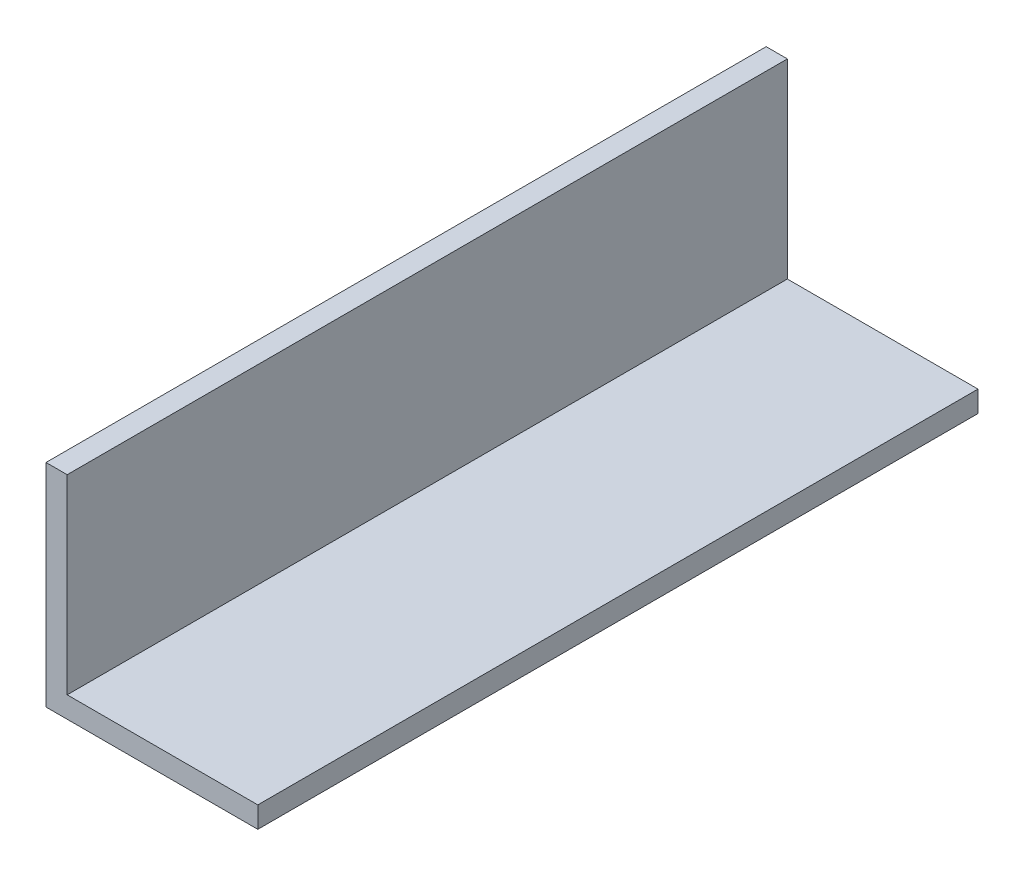
from build123d import *

# Parameters (mm, degrees)
BOSS_EXTRUDE1_DEPTH = 68


with BuildPart() as part:
    # Sketch1 → Boss-Extrude1 (new body)
    with BuildSketch(Plane.XY):
        Polygon((0, 0), (20, 0), (20, 2), (2, 2), (2, 20), (0, 20), align=None)
    extrude(amount=BOSS_EXTRUDE1_DEPTH)


solid = part.part
